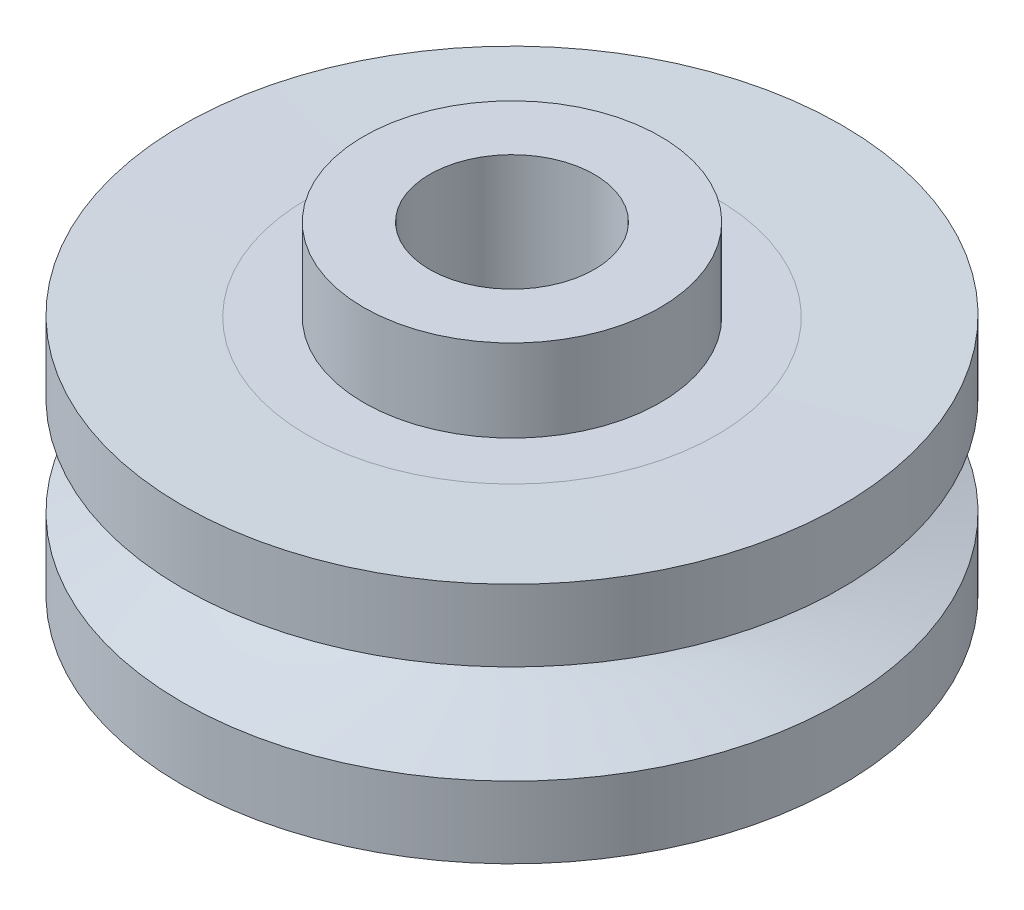
from build123d import *


with BuildPart() as part:
    # 草图1 → 旋转9 (revolve)
    with BuildSketch(Plane.XY, mode=Mode.PRIVATE) as revolve_9_sk:
        with BuildLine():
            Line((1.8, -1.45), (2.483096715, -1.45))
            Line((2.483096715, -1.45), (4, -1.469540433))
            Line((4, -1.469540433), (4, -0.6))
            add(Edge.make_bspline(
                [(4, 0.6), (2.330711219, 0), (4, -0.6)],
                knots=[0, 0, 0, 1, 1, 1], degree=2, weights=[1, 2.566282575, 1]))
            Line((4, 0.6), (4, 1.469540433))
            Line((4, 1.469540433), (2.483096715, 1.45))
            Line((2.483096715, 1.45), (1.8, 1.45))
            Line((1.8, 1.45), (1.8, 2.45))
            Line((1.8, 2.45), (1, 2.45))
            Line((1, 2.45), (1, -2.45))
            Line((1, -2.45), (1.8, -2.45))
            Line((1.8, -2.45), (1.8, -1.45))
        make_face()
    revolve(revolve_9_sk.sketch.rotate(Axis((0, 2.07863921, 0), (0, -1, 0)), 90), axis=Axis((0, 2.07863921, 0), (0, -1, 0)))


solid = part.part
